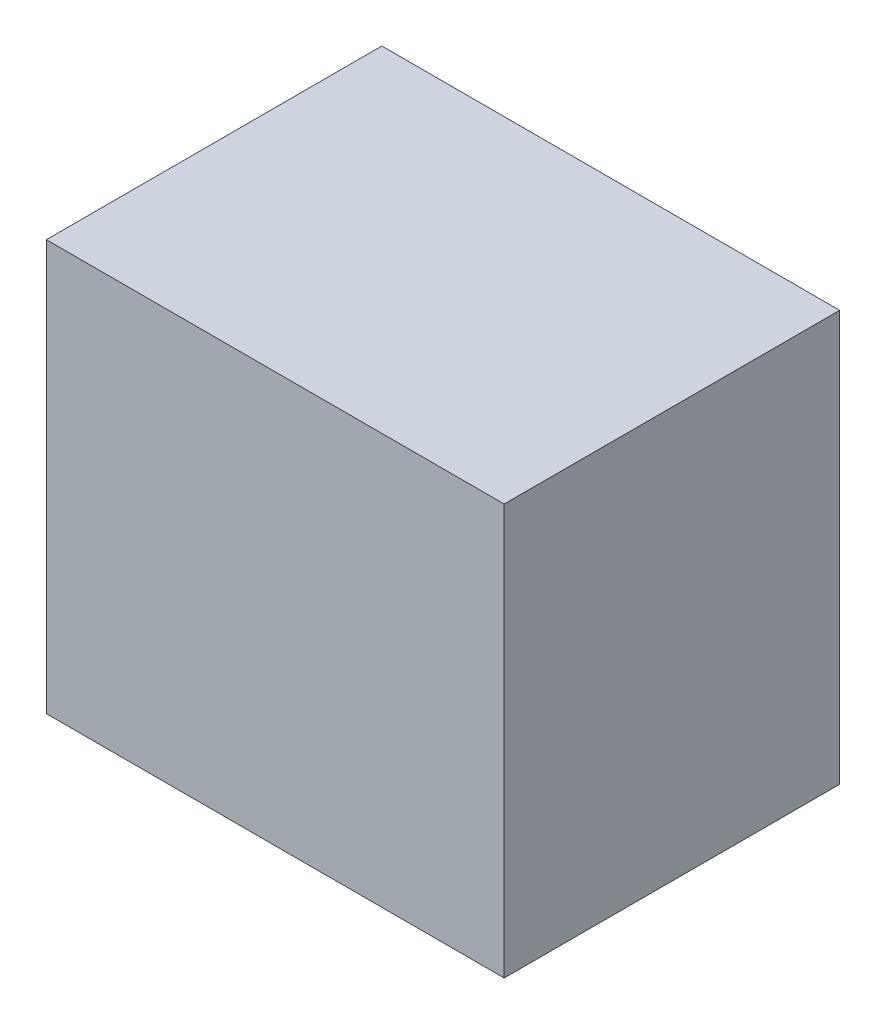
from build123d import *

# Parameters (mm, degrees)
SKETCH1_W           = 11.6
SKETCH1_H           = 8.5
BOSS_EXTRUDE1_DEPTH = 10.4


with BuildPart() as part:
    # Sketch1 → Boss-Extrude1 (new body)
    with BuildSketch(Plane(origin=(0, 0, 0), x_dir=(1, 0, 0), z_dir=(0, 1, 0))):
        Rectangle(SKETCH1_W, SKETCH1_H)
    extrude(amount=BOSS_EXTRUDE1_DEPTH)


solid = part.part
